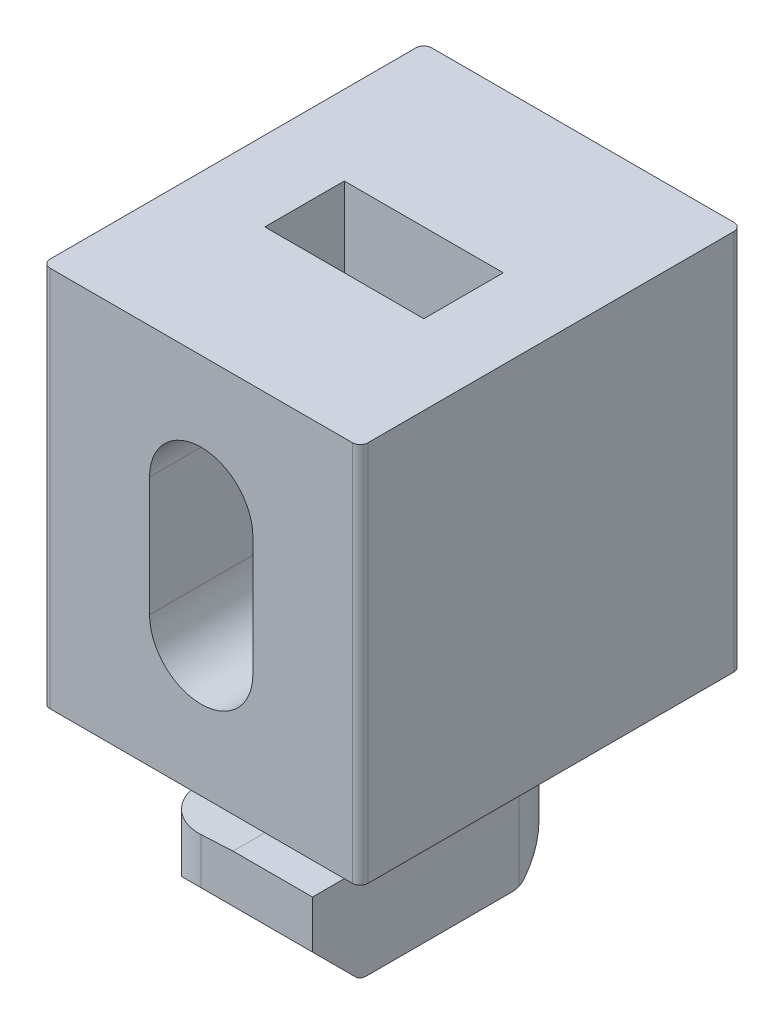
from build123d import *

# Parameters (mm, degrees)
SKETCH_1_W               = 20
SKETCH_1_H               = 24
EXTRUDE_1_DEPTH          = 24
CUT_EXTRUDE_1_DEPTH      = 24
SKETCH_3_W               = 10
SKETCH_3_H               = 5
CUT_EXTRUDE_2_DEPTH      = 20
EXTRUDE_2_DEPTH          = 10
SKETCH_5_W               = 10
SKETCH_5_H               = 16
EXTRUDE_3_DEPTH          = 6
FILLET_2_R               = 0.5
CHAMFER_3_SIZE           = 3
CHAMFER_4_SIZE           = 3
FILLET_3_R               = 1
CUT_EXTRUDE_3_REACH      = 24
CUT_EXTRUDE_3_END_RADIUS = 5
CUT_EXTRUDE_4_REACH      = 20
CUT_EXTRUDE_4_END_RADIUS = 5
FILLET_6_R               = 3
FILLET_7_R               = 3


with BuildPart() as part:
    # 草图1 → 拉伸1 (new body)
    with BuildSketch(Plane.XY):
        with Locations((10, 12)):
            Rectangle(SKETCH_1_W, SKETCH_1_H)
    extrude(amount=EXTRUDE_1_DEPTH)

    # 草图2 → 切除-拉伸1 (cut)
    with BuildSketch(Plane.XY.offset(24)):
        with BuildLine():
            Line((6.75, 15.75), (6.75, 8.25))
            ThreePointArc((6.75, 8.25), (10, 5), (13.25, 8.25))
            Line((13.25, 8.25), (13.25, 15.75))
            ThreePointArc((13.25, 15.75), (10, 19), (6.75, 15.75))
        make_face()
    extrude(amount=-CUT_EXTRUDE_1_DEPTH, mode=Mode.SUBTRACT)

    # 草图3 → 切除-拉伸2 (cut)
    with BuildSketch(Plane(origin=(0, 24, 0), x_dir=(1, 0, 0), z_dir=(0, 1, 0))):
        with Locations((10, -12.5)):
            Rectangle(SKETCH_3_W, SKETCH_3_H)
    extrude(amount=-CUT_EXTRUDE_2_DEPTH, mode=Mode.SUBTRACT)

    # 草图4 → 拉伸2 (add)
    with BuildSketch(Plane.XZ):
        with BuildLine():
            Line((15, 19), (10, 19))
            ThreePointArc((10, 19), (6.464466094, 17.535533906), (5, 14))
            Line((5, 14), (5, 9))
            Line((5, 9), (10, 9))
            ThreePointArc((10, 9), (13.535533906, 10.464466094), (15, 14))
            Line((15, 14), (15, 19))
        make_face()
    extrude(amount=EXTRUDE_2_DEPTH)

    # 草图5 → 拉伸3 (add)
    with BuildSketch(Plane.XZ.offset(10)):
        with Locations((10, 14)):
            Rectangle(SKETCH_5_W, SKETCH_5_H)
    extrude(amount=-EXTRUDE_3_DEPTH)

    # 圆角2
    fillet_2_edges = [part.edges().sort_by_distance(p)[0] for p in [
        (20, 12, 24),
        (0, 12, 24),
        (20, 12, 0),
        (0, 12, 0),
    ]]
    fillet(fillet_2_edges, radius=FILLET_2_R)

    # 倒角3
    chamfer_3_edges = [part.edges().sort_by_distance(p)[0] for p in [
        (10, -10, 22),
    ]]
    chamfer(chamfer_3_edges, length=CHAMFER_3_SIZE)

    # 倒角4
    chamfer_4_edges = [part.edges().sort_by_distance(p)[0] for p in [
        (10, -10, 6),
    ]]
    chamfer(chamfer_4_edges, length=CHAMFER_4_SIZE)

    # 圆角3
    fillet_3_edges = [part.edges().sort_by_distance(p)[0] for p in [
        (10, -10, 19),
        (10, -10, 9),
    ]]
    fillet(fillet_3_edges, radius=FILLET_3_R)

    # 切除-拉伸3: up to this cylinder (the profile starts outside it)
    cut_extrude_3_end = Plane(origin=(10, -4.087346, 14), z_dir=(0, 1, 0)) * Cylinder(CUT_EXTRUDE_3_END_RADIUS, 59, mode=Mode.PRIVATE)
    # 草图8 → 切除-拉伸3 (cut, up to the surface)
    with BuildSketch(Plane.XY.offset(22), mode=Mode.PRIVATE) as cut_extrude_3_sk1:
        Polygon((10, -4), (5, -4), (5, -4.262038896), align=None)
    cut_extrude_3_tool1 = extrude(cut_extrude_3_sk1.sketch, amount=-CUT_EXTRUDE_3_REACH, mode=Mode.PRIVATE) - cut_extrude_3_end
    add(cut_extrude_3_tool1.solids().sort_by_distance((6.666667, -4.087346, 22))[0], mode=Mode.SUBTRACT)

    # 切除-拉伸4: up to this cylinder (the profile starts outside it)
    cut_extrude_4_end = Plane(origin=(10, -4.087346, 14), z_dir=(0, 1, 0)) * Cylinder(CUT_EXTRUDE_4_END_RADIUS, 51, mode=Mode.PRIVATE)
    # 草图9 → 切除-拉伸4 (cut, up to the surface)
    with BuildSketch(Plane(origin=(0, 0, 6), x_dir=(-1, 0, 0), z_dir=(0, 0, -1)), mode=Mode.PRIVATE) as cut_extrude_4_sk1:
        Polygon((-10, -4), (-15, -4), (-15, -4.262038896), align=None)
    cut_extrude_4_tool1 = extrude(cut_extrude_4_sk1.sketch, amount=-CUT_EXTRUDE_4_REACH, mode=Mode.PRIVATE) - cut_extrude_4_end
    add(cut_extrude_4_tool1.solids().sort_by_distance((13.333333, -4.087346, 6))[0], mode=Mode.SUBTRACT)

    # 圆角6
    fillet_6_edges = [part.edges().sort_by_distance(p)[0] for p in [
        (15, -5.631019448, 6),
    ]]
    fillet(fillet_6_edges, radius=FILLET_6_R)

    # 圆角7
    fillet_7_edges = [part.edges().sort_by_distance(p)[0] for p in [
        (5, -5.631019448, 22),
    ]]
    fillet(fillet_7_edges, radius=FILLET_7_R)


solid = part.part
